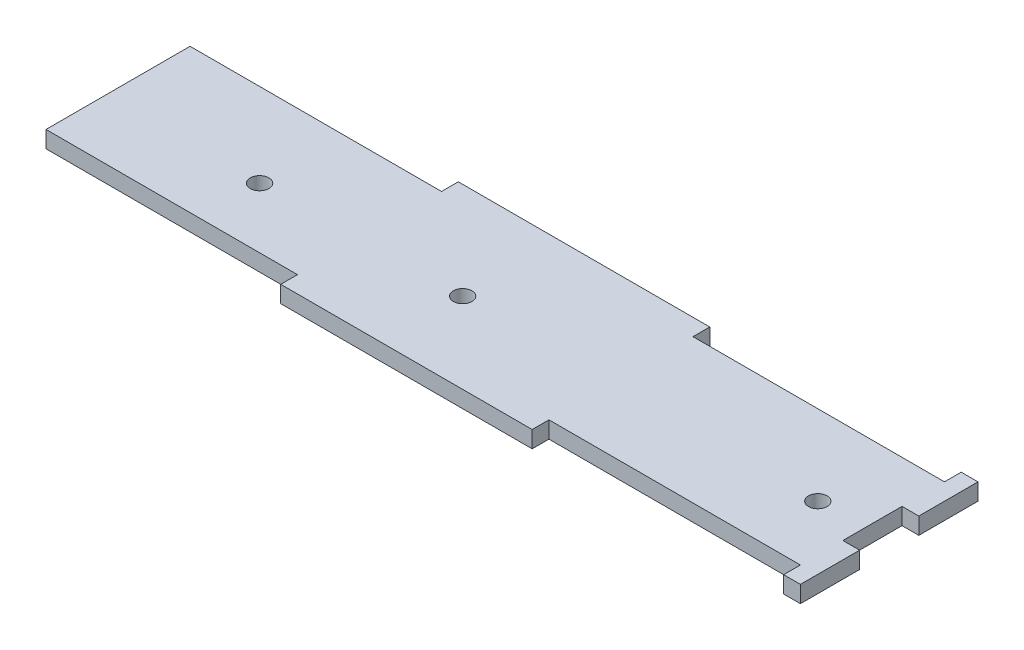
from build123d import *

# Parameters (mm, degrees)
SKETCH1_R           = 1.5
BOSS_EXTRUDE1_DEPTH = 2.7


with BuildPart() as part:
    # Sketch1 → Boss-Extrude1 (new body)
    with BuildSketch(Plane(origin=(0, 0, 0), x_dir=(1, 0, 0), z_dir=(0, 1, 0))):
        Polygon((4, 2.833333333), (4, 12.366666667), (6.7, 12.366666667), (6.7, 21.9), (4, 21.9), (4, 19.2), (-36.5, 19.2), (-36.5, 21.9), (-77, 21.9), (-77, 19.2), (-117.5, 19.2), (-117.5, 12.366666667), (-117.5, 2.833333333), (-117.5, -4), (-77, -4), (-77, -6.7), (-36.5, -6.7), (-36.5, -4), (4, -4), (4, -6.7), (6.7, -6.7), (6.7, 2.833333333), align=None)
        with Locations((-3.5, 6.3)):
            Circle(SKETCH1_R, mode=Mode.SUBTRACT)
        with Locations((-60.7, 6.3)):
            Circle(SKETCH1_R, mode=Mode.SUBTRACT)
        with Locations((-92.8, 5.7)):
            Circle(SKETCH1_R, mode=Mode.SUBTRACT)
    extrude(amount=BOSS_EXTRUDE1_DEPTH)


solid = part.part
